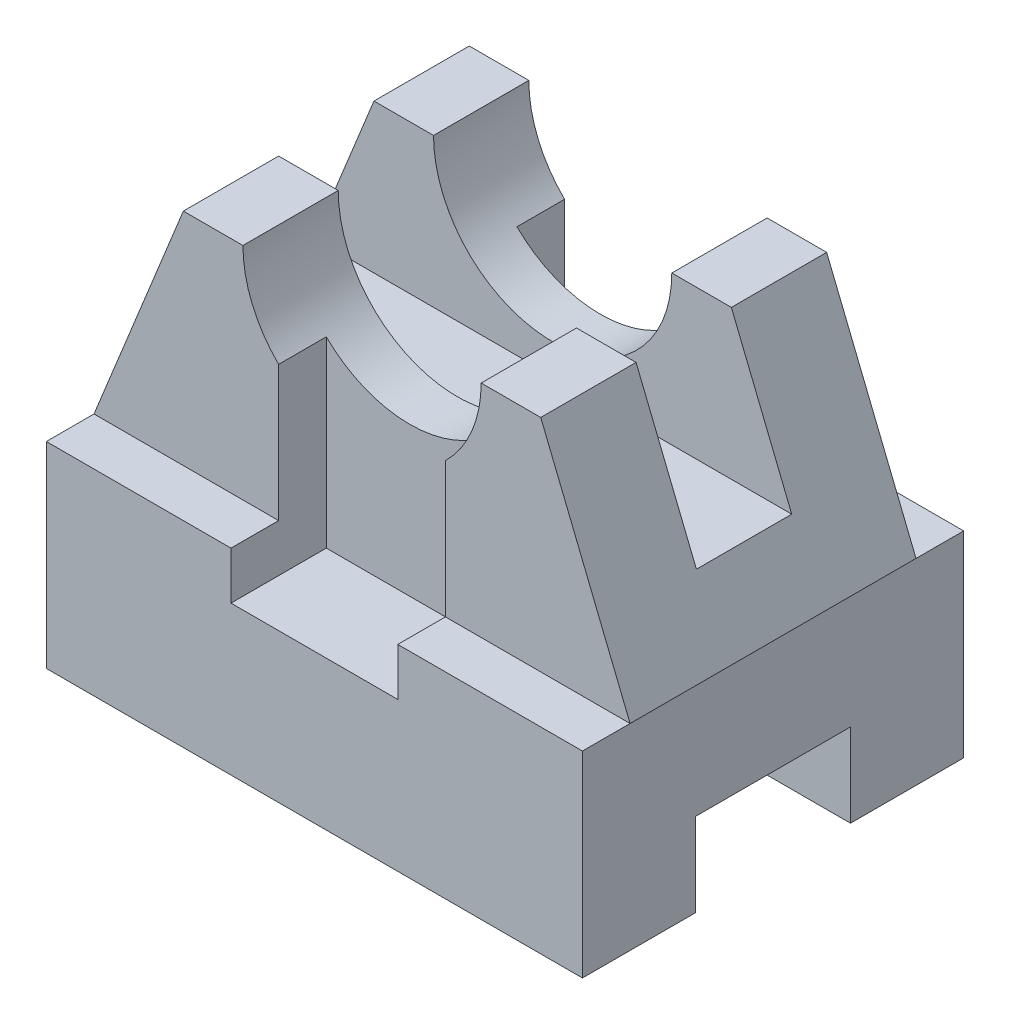
from build123d import *

# Parameters (mm, degrees)
SKETCH1_W           = 90
SKETCH1_H           = 64
BOSS_EXTRUDE1_DEPTH = 70
SKETCH2_W           = 26
SKETCH2_H           = 14
CUT_EXTRUDE1_DEPTH  = 90
CUT_EXTRUDE3_START  = -91
CUT_EXTRUDE3_DEPTH  = 92
SKETCH7_R           = 20
CUT_EXTRUDE4_DEPTH  = 48
CUT_EXTRUDE5_START  = -57
CUT_EXTRUDE5_DEPTH  = 66
SKETCH11_W          = 90
SKETCH11_H          = 16
CUT_EXTRUDE7_DEPTH  = 25
SKETCH13_W          = 28
SKETCH13_H          = 16
CUT_EXTRUDE8_DEPTH  = 45


with BuildPart() as part:
    # Sketch1 → Boss-Extrude1 (new body)
    with BuildSketch(Plane(origin=(0, 0, 0), x_dir=(1, 0, 0), z_dir=(0, 1, 0))):
        with Locations((-0.872093023, 32)):
            Rectangle(SKETCH1_W, SKETCH1_H)
    extrude(amount=BOSS_EXTRUDE1_DEPTH)

    # Sketch2 → Cut-Extrude1 (cut)
    with BuildSketch(Plane.ZY.offset(45.872093023)):
        with Locations((-32, 7)):
            Rectangle(SKETCH2_W, SKETCH2_H)
    extrude(amount=-CUT_EXTRUDE1_DEPTH, mode=Mode.SUBTRACT)

    # Sketch3 → Cut-Extrude3 (cut)
    with BuildSketch(Plane.ZY.offset(45.872093023).offset(CUT_EXTRUDE3_START)):
        Polygon((189.287478648, 33), (0, 33), (-8, 33), (-8, 70), (-8, 259.287478648), (277.352473671, 508.070444427), (474.639952319, 281.782965778), align=None)
    cut_extrude3 = extrude(amount=CUT_EXTRUDE3_DEPTH, mode=Mode.SUBTRACT)

    # Mirror2: Cut-Extrude3 across plane
    add(cut_extrude3.mirror(Plane(origin=(0, 0, -32), x_dir=(1, 0, 0), z_dir=(0, 0, -1))), mode=Mode.SUBTRACT)

    # Sketch7 → Cut-Extrude4 (cut)
    with BuildSketch(Plane.XY.offset(-8)):
        with Locations((-0.872093023, 70)):
            Circle(SKETCH7_R)
    extrude(amount=-CUT_EXTRUDE4_DEPTH, mode=Mode.SUBTRACT)

    # Sketch8 → Cut-Extrude5 (cut)
    with BuildSketch(Plane.XY.offset(-8).offset(CUT_EXTRUDE5_START)):
        Polygon((-126.717387311, -166.418392575), (-45.872093023, 33), (-30.872093023, 70), (49.973201264, 269.418392575), (-348.863583887, 431.10898115), (-525.554172461, -4.727804001), align=None)
    cut_extrude5 = extrude(amount=CUT_EXTRUDE5_DEPTH, mode=Mode.SUBTRACT)

    # Mirror3: Cut-Extrude5 across plane
    add(cut_extrude5.mirror(Plane(origin=(-0.872093023, 0, 0), x_dir=(0, 0, 1), z_dir=(1, 0, 0))), mode=Mode.SUBTRACT)

    # Sketch11 → Cut-Extrude7 (cut)
    with BuildSketch(Plane(origin=(0, 70, 0), x_dir=(1, 0, 0), z_dir=(0, 1, 0))):
        with Locations((-0.872093023, 32)):
            Rectangle(SKETCH11_W, SKETCH11_H)
    extrude(amount=-CUT_EXTRUDE7_DEPTH, mode=Mode.SUBTRACT)

    # Sketch13 → Cut-Extrude8 (cut)
    with BuildSketch(Plane(origin=(0, 70, 0), x_dir=(-1, 0, 0), z_dir=(0, -1, 0))):
        with Locations((0.872093023, 8)):
            Rectangle(SKETCH13_W, SKETCH13_H)
    cut_extrude8 = extrude(amount=CUT_EXTRUDE8_DEPTH, mode=Mode.SUBTRACT)

    # Mirror4: Cut-Extrude8 across plane
    add(cut_extrude8.mirror(Plane(origin=(0, 0, -32), x_dir=(1, 0, 0), z_dir=(0, 0, -1))), mode=Mode.SUBTRACT)


solid = part.part
